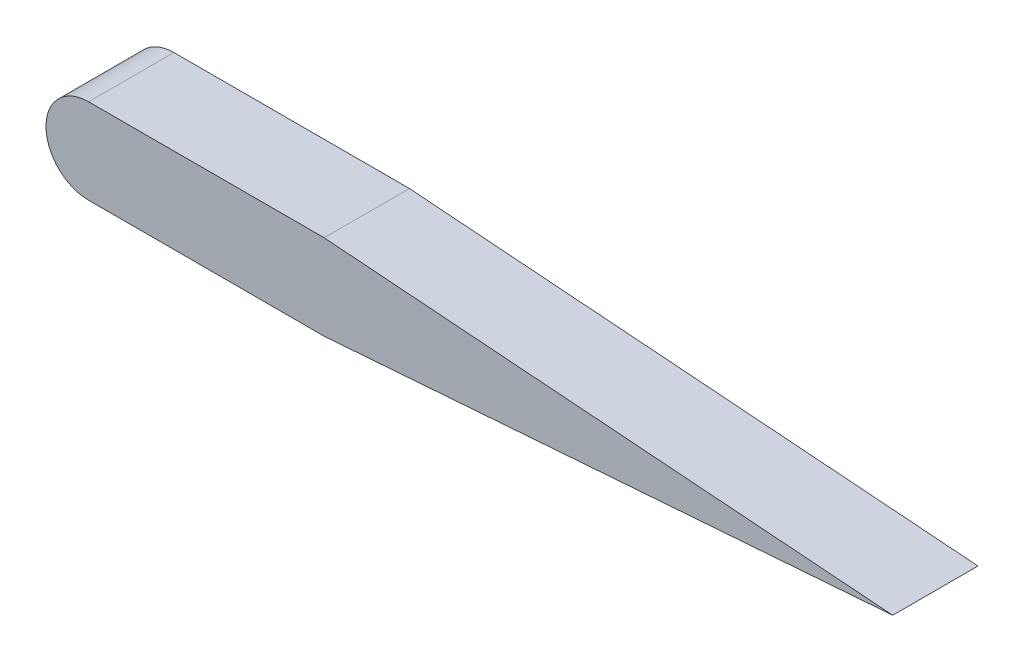
from build123d import *

# Parameters (mm, degrees)
BOSS_EXTRUDE1_DEPTH = 3.175


with BuildPart() as part:
    # Sketch1 → Boss-Extrude1 (new body)
    with BuildSketch(Plane.XY):
        with BuildLine():
            Line((-4.533681302, 1.5875), (4.233333333, 1.5875))
            Line((4.233333333, 1.5875), (25.4, 0))
            Line((25.4, 0), (4.233333333, -1.5875))
            Line((4.233333333, -1.5875), (-4.533681302, -1.5875))
            ThreePointArc((-4.533681302, -1.5875), (-6.121181302, 0), (-4.533681302, 1.5875))
        make_face()
    extrude(amount=BOSS_EXTRUDE1_DEPTH)


solid = part.part
